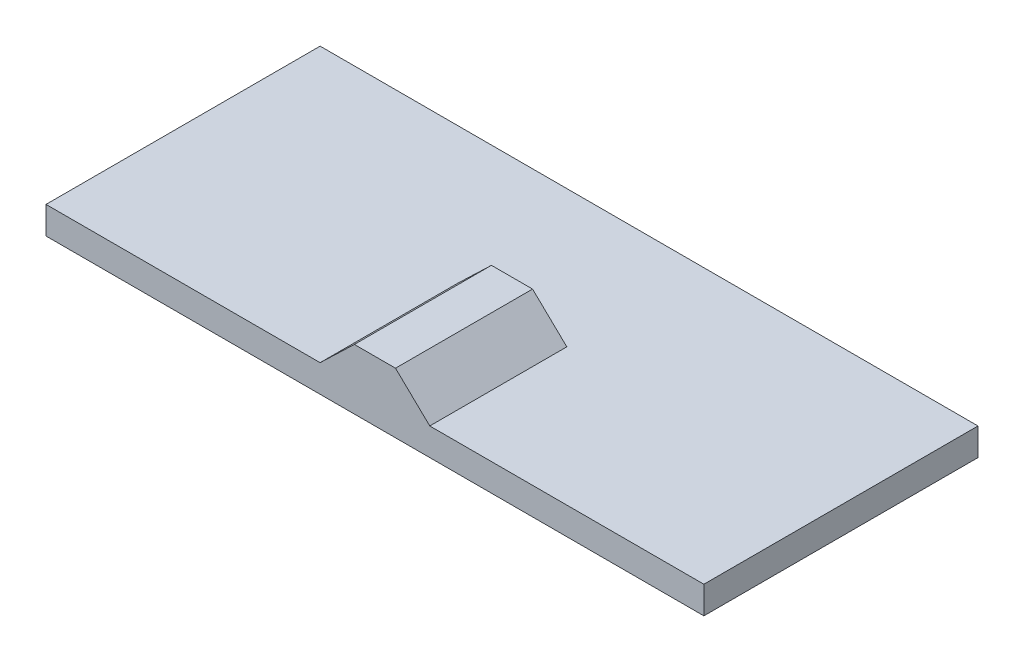
from build123d import *

# Parameters (mm, degrees)
SKETCH1_W           = 3600
SKETCH1_H           = 1500
BOSS_EXTRUDE1_DEPTH = 150
BOSS_EXTRUDE2_DEPTH = 750


with BuildPart() as part:
    # Sketch1 → Boss-Extrude1 (new body)
    with BuildSketch(Plane(origin=(0, 0, 0), x_dir=(1, 0, 0), z_dir=(0, 1, 0))):
        Rectangle(SKETCH1_W, SKETCH1_H)
    extrude(amount=BOSS_EXTRUDE1_DEPTH)

    # Sketch3 → Boss-Extrude2 (add)
    with BuildSketch(Plane.XY.offset(750)):
        Polygon((300, 150), (-300, 150), (-112.5, 330), (112.5, 330), align=None)
    extrude(amount=-BOSS_EXTRUDE2_DEPTH)


solid = part.part
